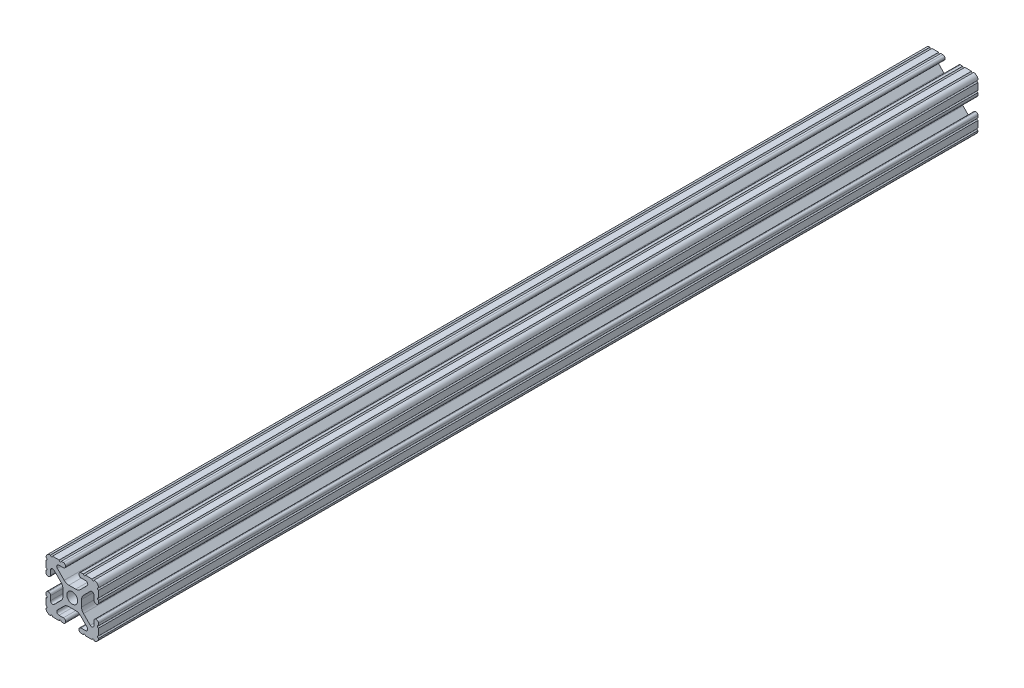
from build123d import *

# Parameters (mm, degrees)
SKETCH1_R           = 2.6035
BOSS_EXTRUDE1_DEPTH = 212.725


with BuildPart() as part:
    # Sketch1 → Boss-Extrude1 (new body, symmetric)
    with BuildSketch(Plane.XY):
        with BuildLine():
            Line((-7.179650497, -8.645192506), (-3.952270251, -5.423690499))
            ThreePointArc((-3.952270251, -5.423690499), (-2.922936451, -4.736929036), (-1.709253557, -4.4958))
            Line((-1.709253557, -4.4958), (1.709253557, -4.4958))
            ThreePointArc((1.709253557, -4.4958), (2.922936451, -4.736929036), (3.952270251, -5.423690499))
            Line((3.952270251, -5.423690499), (7.179650497, -8.645192506))
            ThreePointArc((7.179650497, -8.645192506), (7.41473083, -9.822813117), (6.416408329, -10.4902))
            Line((6.416408329, -10.4902), (4.287512407, -10.4902))
            ThreePointArc((4.287512407, -10.4902), (3.54574862, -10.79744862), (3.2385, -11.539212407))
            Line((3.2385, -11.539212407), (3.2385, -11.650987593))
            ThreePointArc((3.2385, -11.650987593), (3.54574862, -12.39275138), (4.287512407, -12.7))
            Line((4.287512407, -12.7), (5.317126718, -12.7))
            ThreePointArc((5.317126718, -12.7), (5.825126718, -12.192), (6.333126718, -12.7))
            Line((6.333126718, -12.7), (9.550443118, -12.7))
            ThreePointArc((9.550443118, -12.7), (10.058366869, -12.192000006), (10.566443095, -12.699847501))
            ThreePointArc((10.566443095, -12.699847501), (12.082537762, -12.08250727), (12.699846982, -10.566399977))
            ThreePointArc((12.699846982, -10.566399977), (12.192000006, -10.058323491), (12.7, -9.5504))
            Line((12.7, -9.5504), (12.7, -6.3330836))
            ThreePointArc((12.7, -6.3330836), (12.192, -5.8250836), (12.7, -5.3170836))
            Line((12.7, -5.3170836), (12.7, -4.287469289))
            ThreePointArc((12.7, -4.287469289), (12.39275138, -3.545705502), (11.650987593, -3.238456882))
            Line((11.650987593, -3.238456882), (11.539212407, -3.238456882))
            ThreePointArc((11.539212407, -3.238456882), (10.79744862, -3.545705502), (10.4902, -4.287469289))
            Line((10.4902, -4.287469289), (10.4902, -6.402089023))
            ThreePointArc((10.4902, -6.402089023), (9.856505071, -7.351067942), (8.737131347, -7.129408934))
            Line((8.737131347, -7.129408934), (5.441005833, -3.840816462))
            ThreePointArc((5.441005833, -3.840816462), (4.750877967, -2.809883091), (4.5085, -1.593185507))
            Line((4.5085, -1.593185507), (4.5085, 1.593185507))
            ThreePointArc((4.5085, 1.593185507), (4.750877967, 2.809883091), (5.441005833, 3.840816462))
            Line((5.441005833, 3.840816462), (8.737131347, 7.129408934))
            ThreePointArc((8.737131347, 7.129408934), (9.856505071, 7.351067942), (10.4902, 6.402089023))
            Line((10.4902, 6.402089023), (10.4902, 4.287469289))
            ThreePointArc((10.4902, 4.287469289), (10.79744862, 3.545705502), (11.539212407, 3.238456882))
            Line((11.539212407, 3.238456882), (11.650987593, 3.238456882))
            ThreePointArc((11.650987593, 3.238456882), (12.39275138, 3.545705502), (12.7, 4.287469289))
            Line((12.7, 4.287469289), (12.7, 5.3170836))
            ThreePointArc((12.7, 5.3170836), (12.192, 5.8250836), (12.7, 6.3330836))
            Line((12.7, 6.3330836), (12.7, 9.5504))
            ThreePointArc((12.7, 9.5504), (12.192000006, 10.058323491), (12.699846982, 10.566399977))
            ThreePointArc((12.699846982, 10.566399977), (12.082537762, 12.08250727), (10.566443095, 12.699847501))
            ThreePointArc((10.566443095, 12.699847501), (10.058366869, 12.192000006), (9.550443118, 12.7))
            Line((9.550443118, 12.7), (6.333126718, 12.7))
            ThreePointArc((6.333126718, 12.7), (5.825126718, 12.192), (5.317126718, 12.7))
            Line((5.317126718, 12.7), (4.287512407, 12.7))
            ThreePointArc((4.287512407, 12.7), (3.54574862, 12.39275138), (3.2385, 11.650987593))
            Line((3.2385, 11.650987593), (3.2385, 11.539212407))
            ThreePointArc((3.2385, 11.539212407), (3.54574862, 10.79744862), (4.287512407, 10.4902))
            Line((4.287512407, 10.4902), (6.476788598, 10.4902))
            ThreePointArc((6.476788598, 10.4902), (7.432222385, 9.85140422), (7.207036008, 8.724370562))
            Line((7.207036008, 8.724370562), (3.898272566, 5.423169045))
            ThreePointArc((3.898272566, 5.423169045), (2.869120213, 4.736787962), (1.655778399, 4.4958))
            Line((1.655778399, 4.4958), (-1.655778399, 4.4958))
            ThreePointArc((-1.655778399, 4.4958), (-2.869120213, 4.736787962), (-3.898272566, 5.423169045))
            Line((-3.898272566, 5.423169045), (-7.207036008, 8.724370562))
            ThreePointArc((-7.207036008, 8.724370562), (-7.432222385, 9.85140422), (-6.476788598, 10.4902))
            Line((-6.476788598, 10.4902), (-4.287512407, 10.4902))
            ThreePointArc((-4.287512407, 10.4902), (-3.54574862, 10.79744862), (-3.2385, 11.539212407))
            Line((-3.2385, 11.539212407), (-3.2385, 11.650987593))
            ThreePointArc((-3.2385, 11.650987593), (-3.54574862, 12.39275138), (-4.287512407, 12.7))
            Line((-4.287512407, 12.7), (-5.317126718, 12.7))
            ThreePointArc((-5.317126718, 12.7), (-5.825126718, 12.192), (-6.333126718, 12.7))
            Line((-6.333126718, 12.7), (-9.550443118, 12.7))
            ThreePointArc((-9.550443118, 12.7), (-10.058366869, 12.192000006), (-10.566443095, 12.699847501))
            ThreePointArc((-10.566443095, 12.699847501), (-12.082537762, 12.08250727), (-12.699846982, 10.566399977))
            ThreePointArc((-12.699846982, 10.566399977), (-12.192000006, 10.058323491), (-12.7, 9.5504))
            Line((-12.7, 9.5504), (-12.7, 6.3330836))
            ThreePointArc((-12.7, 6.3330836), (-12.192, 5.8250836), (-12.7, 5.3170836))
            Line((-12.7, 5.3170836), (-12.7, 4.287469289))
            ThreePointArc((-12.7, 4.287469289), (-12.39275138, 3.545705502), (-11.650987593, 3.238456882))
            Line((-11.650987593, 3.238456882), (-11.539212407, 3.238456882))
            ThreePointArc((-11.539212407, 3.238456882), (-10.79744862, 3.545705502), (-10.4902, 4.287469289))
            Line((-10.4902, 4.287469289), (-10.4902, 6.402089023))
            ThreePointArc((-10.4902, 6.402089023), (-9.856505071, 7.351067942), (-8.737131347, 7.129408934))
            Line((-8.737131347, 7.129408934), (-5.441005833, 3.840816462))
            ThreePointArc((-5.441005833, 3.840816462), (-4.750877967, 2.809883091), (-4.5085, 1.593185507))
            Line((-4.5085, 1.593185507), (-4.5085, -1.593185507))
            ThreePointArc((-4.5085, -1.593185507), (-4.750877967, -2.809883091), (-5.441005833, -3.840816462))
            Line((-5.441005833, -3.840816462), (-8.737131347, -7.129408934))
            ThreePointArc((-8.737131347, -7.129408934), (-9.856505071, -7.351067942), (-10.4902, -6.402089023))
            Line((-10.4902, -6.402089023), (-10.4902, -4.287469289))
            ThreePointArc((-10.4902, -4.287469289), (-10.79744862, -3.545705502), (-11.539212407, -3.238456882))
            Line((-11.539212407, -3.238456882), (-11.650987593, -3.238456882))
            ThreePointArc((-11.650987593, -3.238456882), (-12.39275138, -3.545705502), (-12.7, -4.287469289))
            Line((-12.7, -4.287469289), (-12.7, -5.3170836))
            ThreePointArc((-12.7, -5.3170836), (-12.192, -5.8250836), (-12.7, -6.3330836))
            Line((-12.7, -6.3330836), (-12.7, -9.5504))
            ThreePointArc((-12.7, -9.5504), (-12.192000006, -10.058323491), (-12.699846982, -10.566399977))
            ThreePointArc((-12.699846982, -10.566399977), (-12.082537762, -12.08250727), (-10.566443095, -12.699847501))
            ThreePointArc((-10.566443095, -12.699847501), (-10.058366869, -12.192000006), (-9.550443118, -12.7))
            Line((-9.550443118, -12.7), (-6.333126718, -12.7))
            ThreePointArc((-6.333126718, -12.7), (-5.825126718, -12.192), (-5.317126718, -12.7))
            Line((-5.317126718, -12.7), (-4.287512407, -12.7))
            ThreePointArc((-4.287512407, -12.7), (-3.54574862, -12.39275138), (-3.2385, -11.650987593))
            Line((-3.2385, -11.650987593), (-3.2385, -11.539212407))
            ThreePointArc((-3.2385, -11.539212407), (-3.54574862, -10.79744862), (-4.287512407, -10.4902))
            Line((-4.287512407, -10.4902), (-6.416408329, -10.4902))
            ThreePointArc((-6.416408329, -10.4902), (-7.41473083, -9.822813117), (-7.179650497, -8.645192506))
        make_face()
        Circle(SKETCH1_R, mode=Mode.SUBTRACT)
    extrude(amount=BOSS_EXTRUDE1_DEPTH, both=True)


solid = part.part
